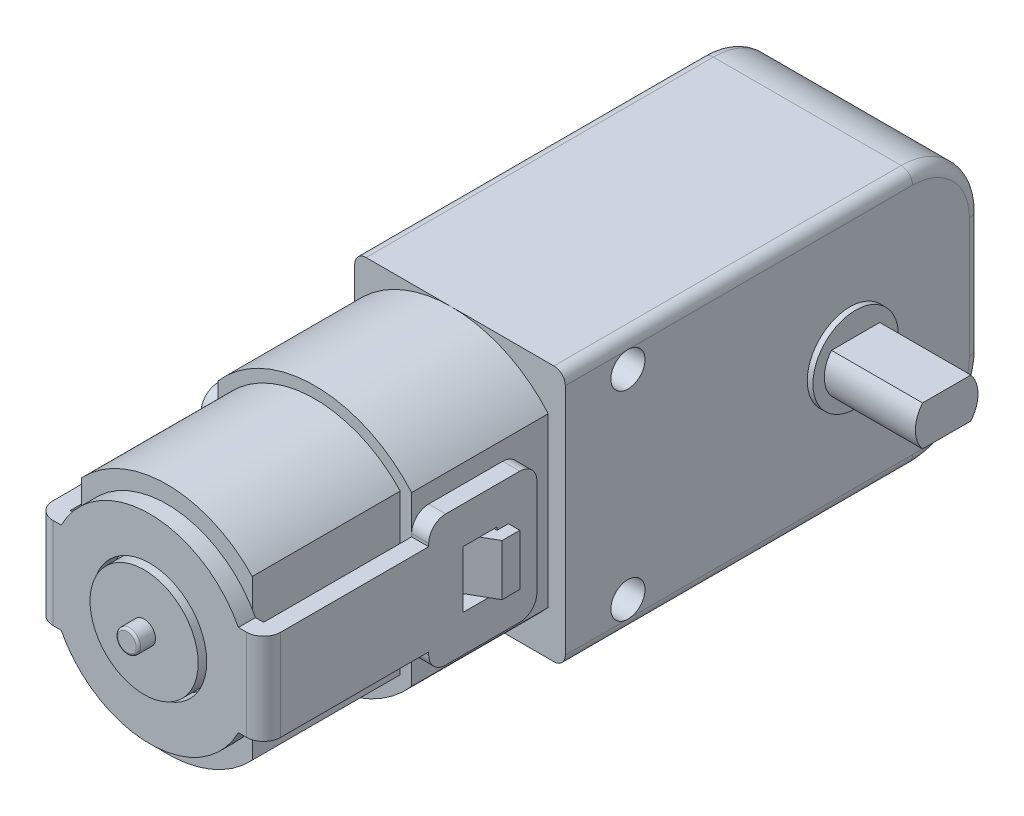
from build123d import *

# Parameters (mm, degrees)
ESBO_O1_W                 = 36.5
ESBO_O1_H                 = 22.5
RESSALTO_EXTRUS_O1_DEPTH  = 9.25
FILETE1_R                 = 6
RESSALTO_EXTRUS_O2_DEPTH  = 12
RESSALTO_EXTRUS_O3_DEPTH  = 13
ESBO_O4_R                 = 3.75
RESSALTO_EXTRUS_O4_DEPTH  = 0.5
ESBO_O5_W                 = 9.5
ESBO_O5_H                 = 11.5
RESSALTO_EXTRUS_O5_DEPTH  = 1.5
ESBO_O6_W                 = 1.5
ESBO_O6_H                 = 8
RESSALTO_EXTRUS_O6_DEPTH  = 13
ESBO_O8_R                 = 4.75
RESSALTO_EXTRUS_O7_DEPTH  = 2
ESBO_O7_R                 = 5
RESSALTO_EXTRUS_O8_DEPTH  = 1.5
ESBO_O10_W                = 1.5
ESBO_O10_H                = 8
RESSALTO_EXTRUS_O9_DEPTH  = 13
ESBO_O11_W                = 1.5
ESBO_O11_H                = 11.5
RESSALTO_EXTRUS_O10_DEPTH = 9.5
FILETE2_R                 = 1.5
ESBO_O12_W                = 3
ESBO_O12_H                = 5
CORTE_EXTRUS_O1_DEPTH     = 21
RESSALTO_EXTRUS_O11_DEPTH = 2.25
ESBO_O15_R                = 1
RESSALTO_EXTRUS_O12_DEPTH = 1.5
RESSALTO_EXTRUS_O13_DEPTH = 8
FILETE4_R                 = 1
ESBO_O17_R                = 1.5
CORTE_EXTRUS_O2_DEPTH     = 22
ESBO_O19_R                = 1.5
RESSALTO_EXTRUS_O14_DEPTH = 1.5
FILETE5_R                 = 1
FILETE6_R                 = 0.2


with BuildPart() as part:
    # Esboço1 → Ressalto-extrusão1 (new body, symmetric)
    with BuildSketch(Plane(origin=(0, 0, 0), x_dir=(0, 0, -1), z_dir=(1, 0, 0))):
        with Locations((-6.75, 0)):
            Rectangle(ESBO_O1_W, ESBO_O1_H)
    extrude(amount=RESSALTO_EXTRUS_O1_DEPTH, both=True)

    # Filete1
    filete1_edges = [part.edges().sort_by_distance(p)[0] for p in [
        (0, -11.25, -11.5),
        (0, 11.25, -11.5),
    ]]
    fillet(filete1_edges, radius=FILETE1_R)

    # Esboço2 → Ressalto-extrusão2 (add)
    with BuildSketch(Plane.XY.offset(25)):
        with BuildLine():
            Line((7.75, 7.369701486), (7.75, -7.369701486))
            ThreePointArc((7.75, -7.369701486), (-0.75, -11.25), (-9.25, -7.369701486))
            Line((-9.25, -7.369701486), (-9.25, 7.369701486))
            ThreePointArc((-9.25, 7.369701486), (-0.75, 11.25), (7.75, 7.369701486))
        make_face()
    extrude(amount=RESSALTO_EXTRUS_O2_DEPTH)

    # Esboço3 → Ressalto-extrusão3 (add)
    with BuildSketch(Plane.XY.offset(37)):
        with BuildLine():
            Line((-8.25, 6.986594306), (-8.25, -6.986594306))
            ThreePointArc((-8.25, -6.986594306), (-0.75, -10.25), (6.75, -6.986594306))
            Line((6.75, -6.986594306), (6.75, 6.986594306))
            ThreePointArc((6.75, 6.986594306), (-0.75, 10.25), (-8.25, 6.986594306))
        make_face()
    extrude(amount=RESSALTO_EXTRUS_O3_DEPTH)

    # Esboço4 → Ressalto-extrusão4 (add)
    with BuildSketch(Plane(origin=(9.25, 0, 0), x_dir=(0, 0, -1), z_dir=(1, 0, 0))):
        Circle(ESBO_O4_R)
    extrude(amount=RESSALTO_EXTRUS_O4_DEPTH)

    # Esboço8 → Ressalto-extrusão7 (add)
    with BuildSketch(Plane.XY.offset(50)):
        with Locations((-0.75, 0)):
            Circle(ESBO_O8_R)
    extrude(amount=RESSALTO_EXTRUS_O7_DEPTH)

    # Esboço14 → Ressalto-extrusão11 (add, symmetric)
    with BuildSketch(Plane(origin=(0, 0, 0), x_dir=(1, 0, 0), z_dir=(0, 1, 0))):
        Polygon((7.75, -33), (10.25, -31.556624327), (10.25, -30), (9.25, -30), (9.25, -31), (7.75, -31), align=None)
    ressalto_extrus_o11 = extrude(amount=RESSALTO_EXTRUS_O11_DEPTH, both=True)

    # Espelhar6: Ressalto-extrusão11 across plane
    add(ressalto_extrus_o11.mirror(Plane(origin=(-0.75, 8.75, 51.5), x_dir=(0, 0, 1), z_dir=(-1, 0, 0))))

    # Esboço15 → Ressalto-extrusão12 (add)
    with BuildSketch(Plane.XY.offset(52)):
        with Locations((-0.75, 0)):
            Circle(ESBO_O15_R)
    extrude(amount=RESSALTO_EXTRUS_O12_DEPTH)

    # Esboço16 → Ressalto-extrusão13 (add)
    with BuildSketch(Plane(origin=(9.75, 0, 0), x_dir=(0, 0, -1), z_dir=(1, 0, 0))):
        with BuildLine():
            Line((-2.121320344, 1.75), (2.121320344, 1.75))
            ThreePointArc((2.121320344, 1.75), (2.75, 0), (2.121320344, -1.75))
            Line((2.121320344, -1.75), (-2.121320344, -1.75))
            ThreePointArc((-2.121320344, -1.75), (-2.75, 0), (-2.121320344, 1.75))
        make_face()
    extrude(amount=RESSALTO_EXTRUS_O13_DEPTH)

    # Filete4
    filete4_edges = [part.edges().sort_by_distance(p)[0] for p in [
        (-9.25, -11.25, 9.75),
        (9.25, -11.25, 9.75),
        (9.25, -9.492640687, -9.742640687),
        (-9.25, -9.492640687, -9.742640687),
        (9.25, 0, -11.5),
        (-9.25, 0, -11.5),
        (9.25, 9.492640687, -9.742640687),
        (-9.25, 9.492640687, -9.742640687),
        (9.25, 11.25, 9.75),
        (-9.25, 11.25, 9.75),
    ]]
    fillet(filete4_edges, radius=FILETE4_R)

    # Esboço17 → Corte-extrusão2 (cut, through all)
    with BuildSketch(Plane(origin=(9.25, 0, 0), x_dir=(0, 0, -1), z_dir=(1, 0, 0))):
        with Locations((-19.5, 8.75)):
            Circle(ESBO_O17_R)
        with Locations((-19.5, -8.75)):
            Circle(ESBO_O17_R)
    extrude(amount=-CORTE_EXTRUS_O2_DEPTH, mode=Mode.SUBTRACT)

    # Esboço19 → Ressalto-extrusão14 (add, symmetric)
    with BuildSketch(Plane(origin=(0, 0, 0), x_dir=(0, 0, -1), z_dir=(1, 0, 0))):
        with BuildLine():
            Line((11.5, 3), (14.450819672, 2.459016393))
            ThreePointArc((14.450819672, 2.459016393), (16.5, 0), (14.450819672, -2.459016393))
            Line((14.450819672, -2.459016393), (11.5, -3))
            Line((11.5, -3), (11.5, 3))
        make_face()
        with Locations((14, 0)):
            Circle(ESBO_O19_R, mode=Mode.SUBTRACT)
    extrude(amount=RESSALTO_EXTRUS_O14_DEPTH, both=True)

    # Filete5
    filete5_edges = [part.edges().sort_by_distance(p)[0] for p in [
        (0, 3, -11.5),
        (0, -3, -11.5),
    ]]
    fillet(filete5_edges, radius=FILETE5_R)

    # Filete6
    filete6_edges = [part.edges().sort_by_distance(p)[0] for p in [
        (-1.75, 0, 53.5),
    ]]
    fillet(filete6_edges, radius=FILETE6_R)


with BuildPart() as body_2:
    # Esboço5 → Ressalto-extrusão5 (new body)
    with BuildSketch(Plane(origin=(7.75, 0, 0), x_dir=(0, 0, -1), z_dir=(1, 0, 0))):
        with Locations((-32.25, 0)):
            Rectangle(ESBO_O5_W, ESBO_O5_H)
    extrude(amount=RESSALTO_EXTRUS_O5_DEPTH)

    # Esboço6 → Ressalto-extrusão6 (add)
    with BuildSketch(Plane.XY.offset(37)):
        with Locations((8.5, 0)):
            Rectangle(ESBO_O6_W, ESBO_O6_H)
    extrude(amount=RESSALTO_EXTRUS_O6_DEPTH)

    # Esboço7 → Ressalto-extrusão8 (add)
    with BuildSketch(Plane.XY.offset(50)):
        with BuildLine():
            Line((9.25, 4), (7.032191208, 4))
            ThreePointArc((7.032191208, 4), (-0.75, 8.75), (-8.532191208, 4))
            Line((-8.532191208, 4), (-10.75, 4))
            Line((-10.75, 4), (-10.75, -4))
            Line((-10.75, -4), (-8.532191208, -4))
            ThreePointArc((-8.532191208, -4), (-0.75, -8.75), (7.032191208, -4))
            Line((7.032191208, -4), (9.25, -4))
            Line((9.25, -4), (9.25, 4))
        make_face()
        with Locations((-0.75, 0)):
            Circle(ESBO_O7_R, mode=Mode.SUBTRACT)
    extrude(amount=RESSALTO_EXTRUS_O8_DEPTH)

    # Esboço10 → Ressalto-extrusão9 (add)
    with BuildSketch(Plane(origin=(0, 0, 50), x_dir=(-1, 0, 0), z_dir=(0, 0, -1))):
        with Locations((10, 0)):
            Rectangle(ESBO_O10_W, ESBO_O10_H)
    extrude(amount=RESSALTO_EXTRUS_O9_DEPTH)

    # Esboço11 → Ressalto-extrusão10 (add)
    with BuildSketch(Plane(origin=(0, 0, 37), x_dir=(-1, 0, 0), z_dir=(0, 0, -1))):
        with Locations((10, 0)):
            Rectangle(ESBO_O11_W, ESBO_O11_H)
    extrude(amount=RESSALTO_EXTRUS_O10_DEPTH)

    # Filete2
    filete2_edges = [body_2.edges().sort_by_distance(p)[0] for p in [
        (8.5, -5.75, 37),
        (8.5, -5.75, 27.5),
        (8.5, 5.75, 27.5),
        (8.5, 5.75, 37),
        (9.25, 0, 51.5),
        (-10.75, 0, 51.5),
        (-10, -5.75, 27.5),
        (-10, -5.75, 37),
        (-10, 5.75, 37),
        (-10, 5.75, 27.5),
    ]]
    fillet(filete2_edges, radius=FILETE2_R)

    # Esboço12 → Corte-extrusão1 (cut, through all)
    with BuildSketch(Plane(origin=(9.25, 0, 0), x_dir=(0, 0, -1), z_dir=(1, 0, 0))):
        with Locations((-32.5, 0)):
            Rectangle(ESBO_O12_W, ESBO_O12_H)
    extrude(amount=-CORTE_EXTRUS_O1_DEPTH, mode=Mode.SUBTRACT)


solid = Compound([part.part, body_2.part])
